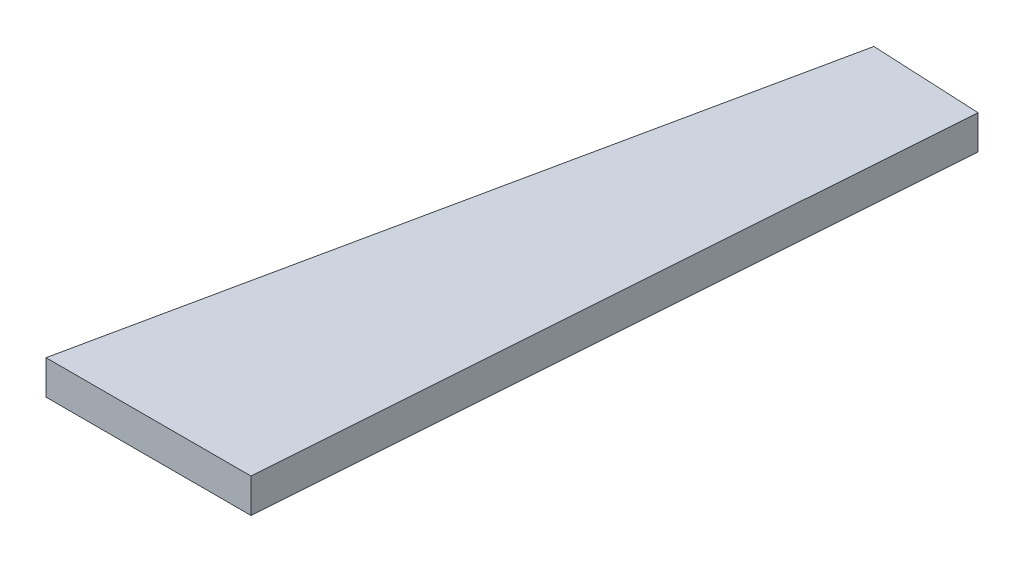
from build123d import *

# Parameters (mm, degrees)
BOSS_EXTRUDE1_DEPTH = 63.5


with BuildPart() as part:
    # Sketch1 → Boss-Extrude1 (new body, symmetric)
    with BuildSketch(Plane(origin=(0, 0, 0), x_dir=(1, 0, 0), z_dir=(0, 1, 0))):
        Polygon((406.4, -19.507017733), (225.291012038, -2540), (-536.708987962, -2540), (0, 0), align=None)
    extrude(amount=BOSS_EXTRUDE1_DEPTH, both=True)


solid = part.part
